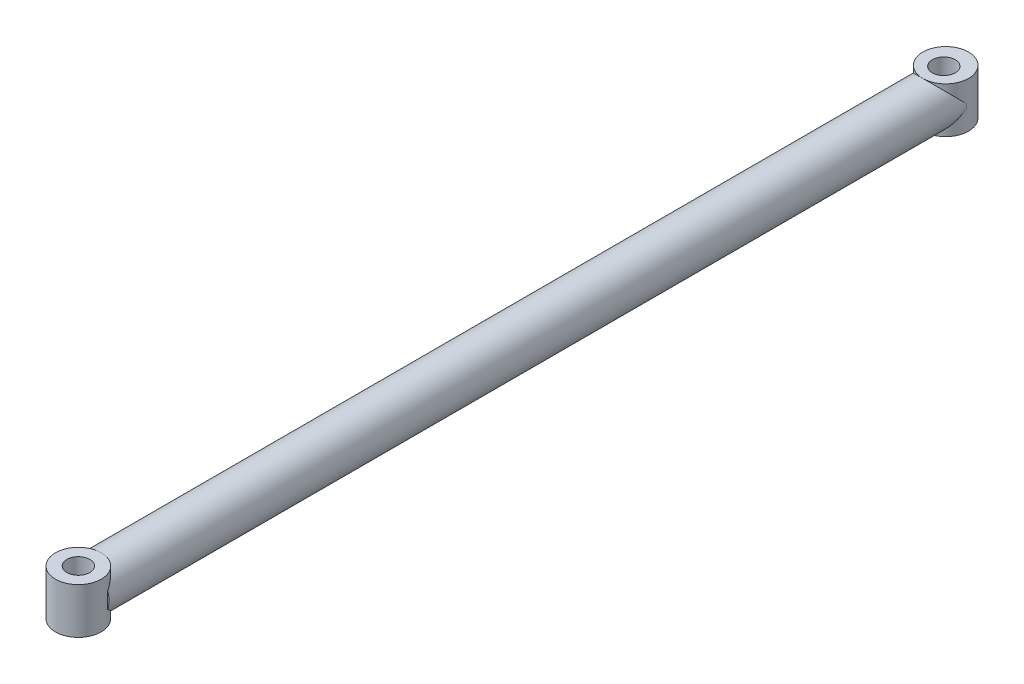
from build123d import *

# Parameters (mm, degrees)
SKIZZE1_R                       = 2
AUFSATZ_LINEAR_AUSTRAGEN1_DEPTH = 75
AUFSATZ_LINEAR_START            = 2
SKIZZE2_R                       = 2
AUFSATZ_LINEAR_AUSTRAGEN2_DEPTH = 4
SKIZZE3_R                       = 1
SCHNITT_LINEAR_AUSTRAGEN1_DEPTH = 4


with BuildPart() as part:
    # Skizze1 → Aufsatz-Linear austragen1 (new body)
    with BuildSketch(Plane.XY):
        Circle(SKIZZE1_R)
    extrude(amount=AUFSATZ_LINEAR_AUSTRAGEN1_DEPTH)

    # Skizze2 → Aufsatz-Linear austragen2 (add)
    with BuildSketch(Plane(origin=(0, 0, 0), x_dir=(1, 0, 0), z_dir=(0, 1, 0)).offset(AUFSATZ_LINEAR_START)):
        with Locations((0, -75.688838901)):
            Circle(SKIZZE2_R)
        with Locations((0, 0.161056254)):
            Circle(SKIZZE2_R)
    extrude(amount=-AUFSATZ_LINEAR_AUSTRAGEN2_DEPTH)

    # Skizze3 → Schnitt-Linear austragen1 (cut)
    with BuildSketch(Plane(origin=(0, 2, 0), x_dir=(1, 0, 0), z_dir=(0, 1, 0))):
        with Locations((0, -75.688838901)):
            Circle(SKIZZE3_R)
        Circle(SKIZZE3_R)
    extrude(amount=-SCHNITT_LINEAR_AUSTRAGEN1_DEPTH, mode=Mode.SUBTRACT)


solid = part.part
